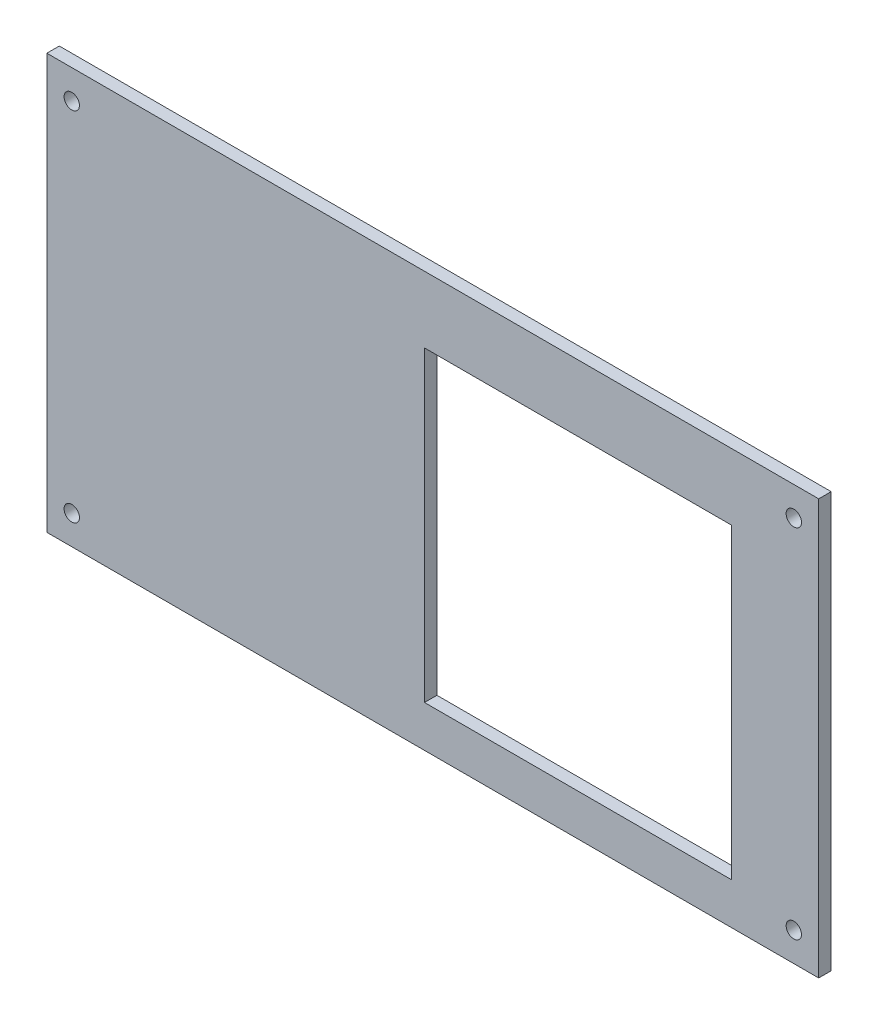
from build123d import *

# Parameters (mm, degrees)
SKETCH1_W           = 186
SKETCH1_H           = 100
BOSS_EXTRUDE1_DEPTH = 3
SKETCH2_W           = 74
SKETCH2_H           = 74
SKETCH2_R           = 1.85
CUT_EXTRUDE1_DEPTH  = 4


with BuildPart() as part:
    # Sketch1 → Boss-Extrude1 (new body)
    with BuildSketch(Plane.XY):
        with Locations((93, 50)):
            Rectangle(SKETCH1_W, SKETCH1_H)
    extrude(amount=BOSS_EXTRUDE1_DEPTH)

    # Sketch2 → Cut-Extrude1 (cut, through all)
    with BuildSketch(Plane(origin=(0, 0, 0), x_dir=(-1, 0, 0), z_dir=(0, 0, -1))):
        with Locations((-128, 47)):
            Rectangle(SKETCH2_W, SKETCH2_H)
        with Locations((-180, 7)):
            Circle(SKETCH2_R)
        with Locations((-180, 93)):
            Circle(SKETCH2_R)
        with Locations((-6, 7)):
            Circle(SKETCH2_R)
        with Locations((-6, 93)):
            Circle(SKETCH2_R)
    extrude(amount=-CUT_EXTRUDE1_DEPTH, mode=Mode.SUBTRACT)


solid = part.part
